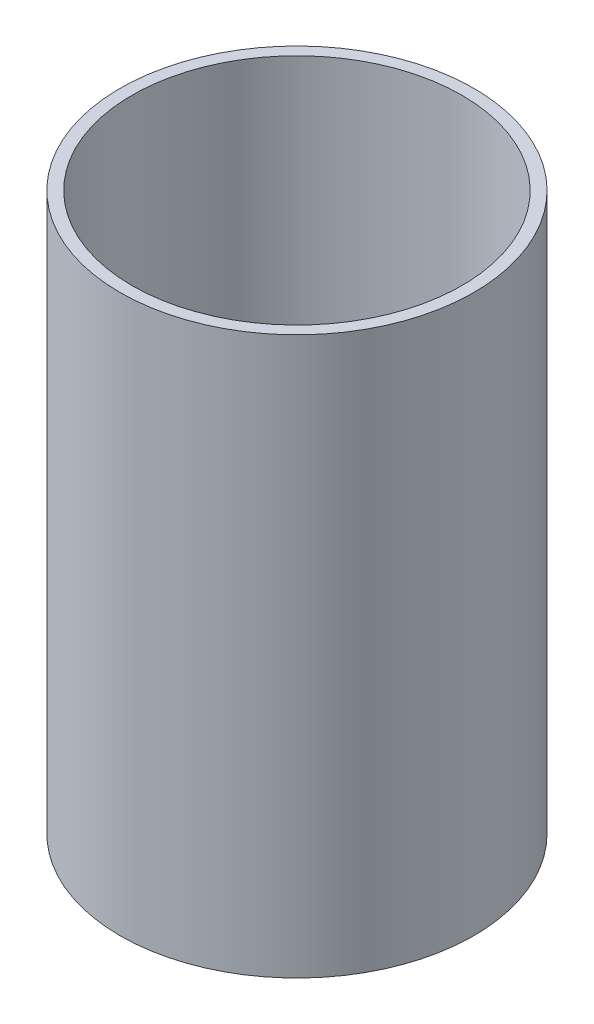
from build123d import *

# Parameters (mm, degrees)
ESBO_O1_R                = 44.45
ESBO_O1_R_2              = 41.45
RESSALTO_EXTRUS_O1_DEPTH = 140


with BuildPart() as part:
    # Esboço1 → Ressalto-extrusão1 (new body)
    with BuildSketch(Plane(origin=(0, 0, 0), x_dir=(1, 0, 0), z_dir=(0, 1, 0))):
        Circle(ESBO_O1_R)
        Circle(ESBO_O1_R_2, mode=Mode.SUBTRACT)
    extrude(amount=RESSALTO_EXTRUS_O1_DEPTH)


solid = part.part
